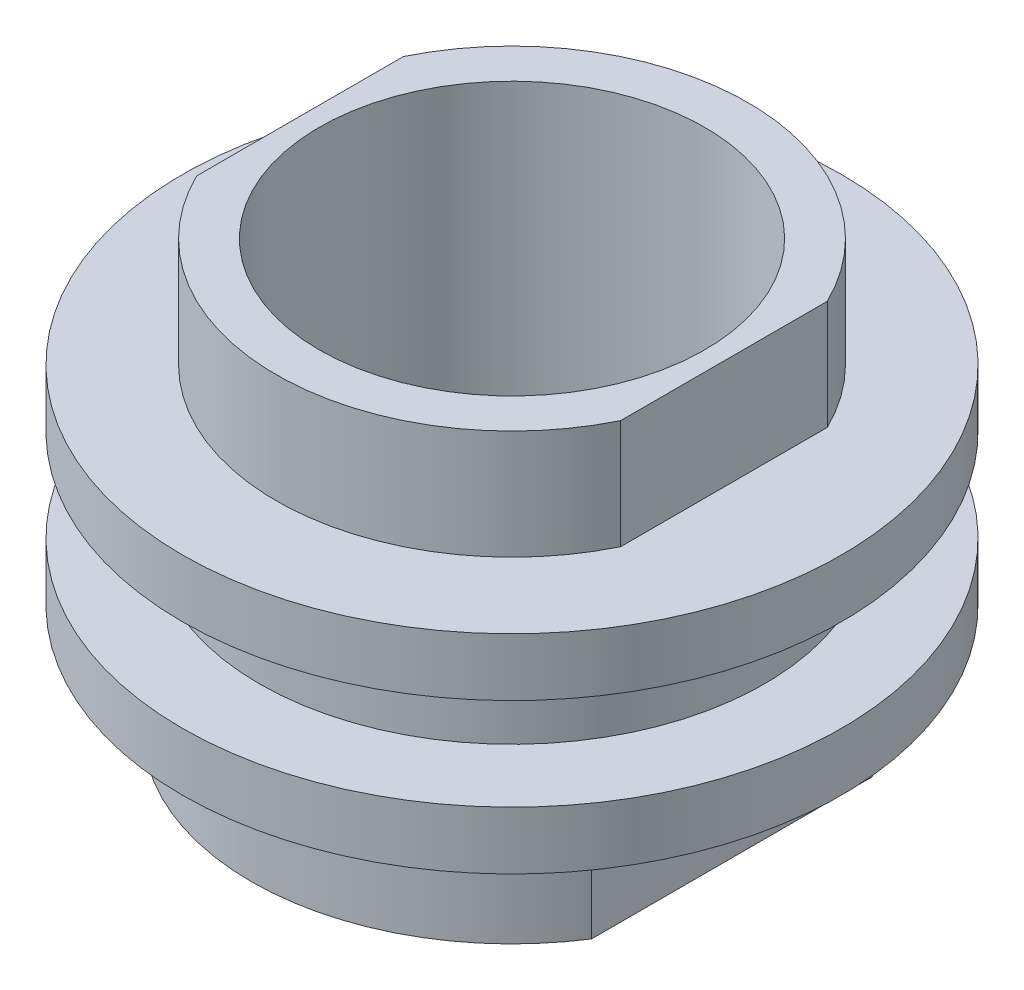
from build123d import *

# Parameters (mm, degrees)
SKETCH1_R           = 4.625
BOSS_EXTRUDE1_DEPTH = 0.845
SKETCH2_R           = 6.035
BOSS_EXTRUDE2_DEPTH = 1.06
SKETCH3_R           = 6.035
BOSS_EXTRUDE3_DEPTH = 1.06
BOSS_EXTRUDE4_DEPTH = 2
BOSS_EXTRUDE5_DEPTH = 2
SKETCH6_R           = 3.5306
CUT_EXTRUDE1_DEPTH  = 8.81


with BuildPart() as part:
    # Sketch1 → Boss-Extrude1 (new body, symmetric)
    with BuildSketch(Plane(origin=(0, 0, 0), x_dir=(1, 0, 0), z_dir=(0, 1, 0))):
        Circle(SKETCH1_R)
    extrude(amount=BOSS_EXTRUDE1_DEPTH, both=True)

    # Sketch2 → Boss-Extrude2 (add)
    with BuildSketch(Plane(origin=(0, 0.845, 0), x_dir=(1, 0, 0), z_dir=(0, 1, 0))):
        Circle(SKETCH2_R)
    extrude(amount=BOSS_EXTRUDE2_DEPTH)

    # Sketch3 → Boss-Extrude3 (add)
    with BuildSketch(Plane.XZ.offset(0.845)):
        Circle(SKETCH3_R)
    extrude(amount=BOSS_EXTRUDE3_DEPTH)

    # Sketch4 → Boss-Extrude4 (add)
    with BuildSketch(Plane(origin=(0, 1.905, 0), x_dir=(1, 0, 0), z_dir=(0, 1, 0))):
        with BuildLine():
            Line((-3.881348315, 1.892157303), (-3.881348315, 0))
            Line((-3.881348315, 0), (-3.881348315, -1.892157303))
            ThreePointArc((-3.881348315, -1.892157303), (0, -4.318), (3.881348315, -1.892157303))
            Line((3.881348315, -1.892157303), (3.881348315, 0))
            Line((3.881348315, 0), (3.881348315, 1.892157303))
            ThreePointArc((3.881348315, 1.892157303), (0, 4.318), (-3.881348315, 1.892157303))
        make_face()
    extrude(amount=BOSS_EXTRUDE4_DEPTH)

    # Sketch5 → Boss-Extrude5 (add)
    with BuildSketch(Plane.XZ.offset(1.905)):
        with BuildLine():
            Line((-4.024811429, 2.569713604), (-4.024811429, 0))
            Line((-4.024811429, 0), (-4.024811429, -2.569713604))
            ThreePointArc((-4.024811429, -2.569713604), (0, -4.7752), (4.024811429, -2.569713604))
            Line((4.024811429, -2.569713604), (4.024811429, 0))
            Line((4.024811429, 0), (4.024811429, 2.569713604))
            ThreePointArc((4.024811429, 2.569713604), (0, 4.7752), (-4.024811429, 2.569713604))
        make_face()
    extrude(amount=BOSS_EXTRUDE5_DEPTH)

    # Sketch6 → Cut-Extrude1 (cut, through all)
    with BuildSketch(Plane(origin=(0, 3.905, 0), x_dir=(1, 0, 0), z_dir=(0, 1, 0))):
        Circle(SKETCH6_R)
    extrude(amount=-CUT_EXTRUDE1_DEPTH, mode=Mode.SUBTRACT)


solid = part.part
